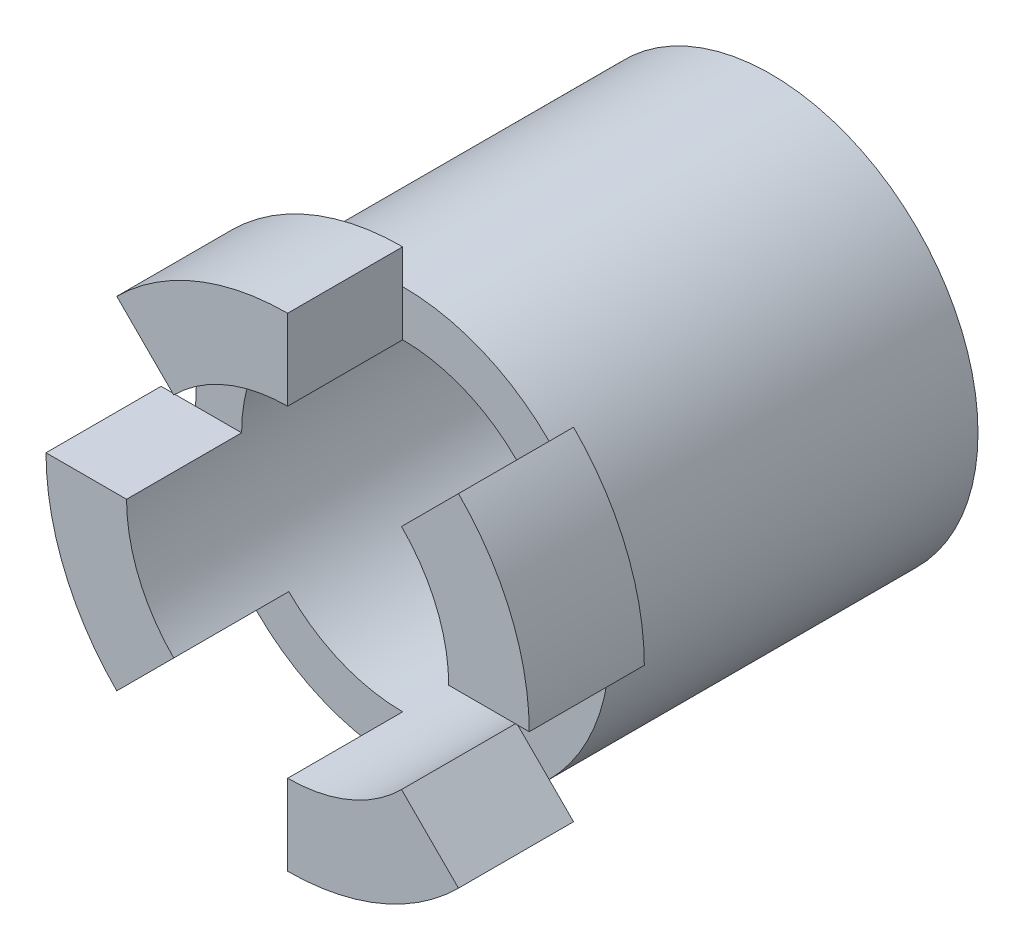
from build123d import *

# Parameters (mm, degrees)
SKETCH1_R           = 4.5
BOSS_EXTRUDE1_DEPTH = 8
SKETCH2_R           = 3.5
CUT_EXTRUDE1_DEPTH  = 6.5
BOSS_EXTRUDE2_DEPTH = 2.5


with BuildPart() as part:
    # Sketch1 → Boss-Extrude1 (new body)
    with BuildSketch(Plane.XY):
        Circle(SKETCH1_R)
    extrude(amount=BOSS_EXTRUDE1_DEPTH)

    # Sketch2 → Cut-Extrude1 (cut)
    with BuildSketch(Plane.XY.offset(8)):
        Circle(SKETCH2_R)
    extrude(amount=-CUT_EXTRUDE1_DEPTH, mode=Mode.SUBTRACT)

    # Sketch3 → Boss-Extrude2 (add)
    with BuildSketch(Plane.XY.offset(8)):
        with BuildLine():
            Line((0, 5.25), (0, 3.5))
            ThreePointArc((0, 3.5), (-1.339392013, 3.233578364), (-2.474873734, 2.474873734))
            Line((-2.474873734, 2.474873734), (-3.712310601, 3.712310601))
            ThreePointArc((-3.712310601, 3.712310601), (-2.00908802, 4.850367546), (0, 5.25))
        make_face()
        with BuildLine():
            Line((-5.25, 0), (-3.5, 0))
            ThreePointArc((-3.5, 0), (-3.233578364, -1.339392013), (-2.474873734, -2.474873734))
            Line((-2.474873734, -2.474873734), (-3.712310601, -3.712310601))
            ThreePointArc((-3.712310601, -3.712310601), (-4.850367546, -2.00908802), (-5.25, 0))
        make_face()
        with BuildLine():
            Line((2.474873734, 2.474873734), (3.712310601, 3.712310601))
            ThreePointArc((3.712310601, 3.712310601), (4.850367546, 2.00908802), (5.25, 0))
            Line((5.25, 0), (3.5, 0))
            ThreePointArc((3.5, 0), (3.233578364, 1.339392013), (2.474873734, 2.474873734))
        make_face()
        with BuildLine():
            Line((0, -3.5), (0, -5.25))
            ThreePointArc((0, -5.25), (2.00908802, -4.850367546), (3.712310601, -3.712310601))
            Line((3.712310601, -3.712310601), (2.474873734, -2.474873734))
            ThreePointArc((2.474873734, -2.474873734), (1.339392013, -3.233578364), (0, -3.5))
        make_face()
    extrude(amount=BOSS_EXTRUDE2_DEPTH)


solid = part.part
